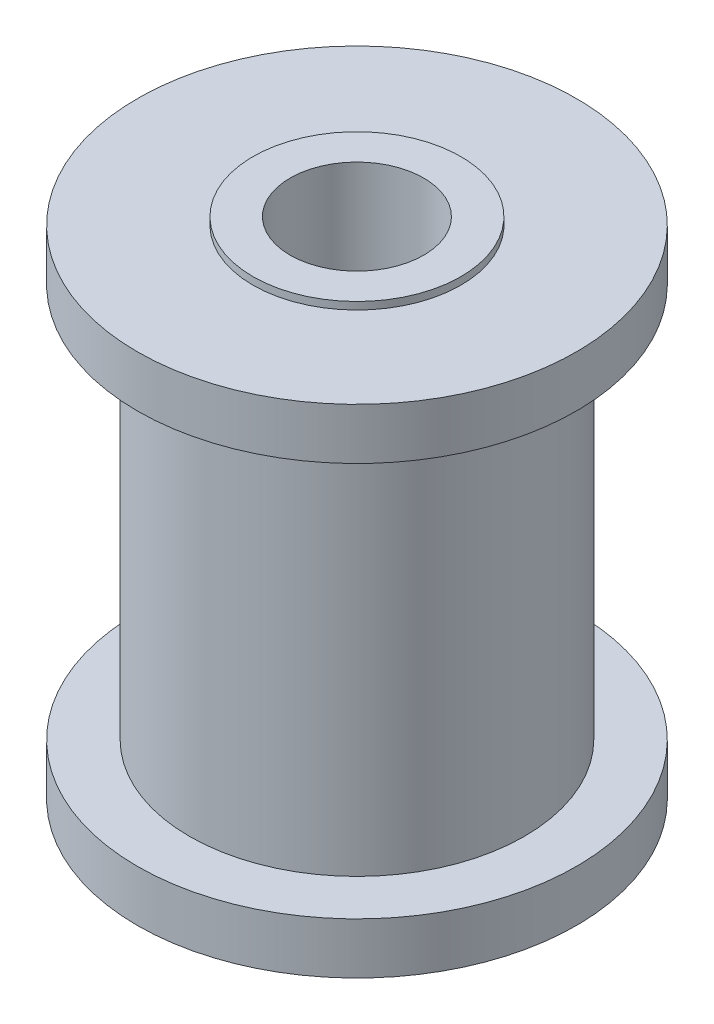
from build123d import *


with BuildPart() as part:
    # Sketch2 → Revolve1 (revolve)
    with BuildSketch(Plane(origin=(0, 0, 0), x_dir=(0, 0, -1), z_dir=(1, 0, 0))):
        Polygon((2.286, 0.9906), (3.556, 0.9906), (3.556, 0.7366), (7.5057, 0.7366), (7.5057, -1.016), (5.7277, -1.016), (5.7277, -14.5034), (7.5057, -14.5034), (7.5057, -16.256), (3.556, -16.256), (3.556, -16.51), (2.286, -16.51), align=None)
    revolve(axis=Axis((0, 55, 0), (0, -1, 0)))


solid = part.part
